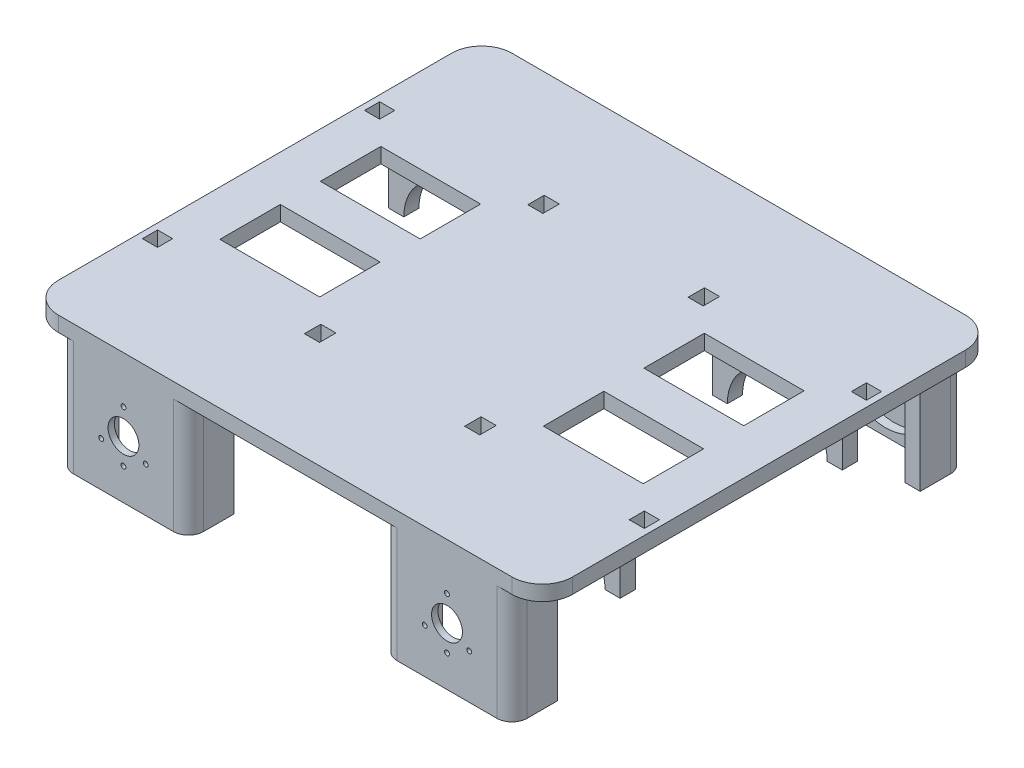
from build123d import *

# Parameters (mm, degrees)
SKETCH1_W                        = 170
SKETCH1_H                        = 150
BOSS_EXTRUDE1_DEPTH              = 5
FILLET1_R                        = 10
BOSS_EXTRUDE2_DEPTH              = 38
SKETCH29_W                       = 43
SKETCH29_H                       = 5
BOSS_EXTRUDE3_DEPTH              = 19
CUT_EXTRUDE1_START               = -2.9
SKETCH6_R                        = 16.5
CUT_EXTRUDE1_DEPTH               = 93.9
SKETCH13_R                       = 5.1
CUT_EXTRUDE2_DEPTH               = 4.7
TAP_DRILL_FOR_M2_TAP1_AT_2_COUNT = 2
TAP_DRILL_FOR_M2_TAP1_AT_2_PITCH = 8.5
TAP_DRILL_FOR_M2_TAP1_AT_3_COUNT = 2
TAP_DRILL_FOR_M2_TAP1_AT_3_PITCH = 14.722431864
TAP_DRILL_FOR_M2_TAP1_AT_4_COUNT = 2
TAP_DRILL_FOR_M2_TAP1_AT_4_PITCH = 14.722431864
FILLET2_R                        = 5
SKETCH28_W                       = 33
SKETCH28_H                       = 20
CUT_EXTRUDE3_DEPTH               = 10
MIRROR25_COPY_1_DEPTH            = 38
MIRROR25_COPY_2_DEPTH            = 38
MIRROR25_START                   = -2.9
MIRROR25_COPY_3_SKETCH_R         = 16.5
MIRROR25_COPY_3_DEPTH            = 93.9
MIRROR25_COPY_4_SKETCH_R         = 5.1
MIRROR25_COPY_4_DEPTH            = 4.7
MIRROR25_COPY_5_SKETCH_R         = 16.5
MIRROR25_COPY_5_DEPTH            = 93.9
MIRROR25_COPY_6_SKETCH_R         = 5.1
MIRROR25_COPY_6_DEPTH            = 4.7
MIRROR25_COPY_15_SKETCH_W        = 33
MIRROR25_COPY_15_SKETCH_H        = 20
MIRROR25_COPY_15_DEPTH           = 10
MIRROR25_COPY_16_SKETCH_W        = 33
MIRROR25_COPY_16_SKETCH_H        = 20
MIRROR25_COPY_16_DEPTH           = 10
FILLET4_R                        = 5
SKETCH33_W                       = 5
SKETCH33_H                       = 5.425553346
CUT_EXTRUDE4_DEPTH               = 10
CUT_EXTRUDE5_START               = -11
SKETCH34_W                       = 5
SKETCH34_H                       = 5
CUT_EXTRUDE5_DEPTH               = 28
MIRROR29_COPY_1_SKETCH_W         = 43
MIRROR29_COPY_1_SKETCH_H         = 5
MIRROR29_COPY_1_DEPTH            = 19
MIRROR29_START                   = -2.9
MIRROR29_COPY_2_SKETCH_R         = 16.5
MIRROR29_COPY_2_DEPTH            = 93.9
MIRROR29_COPY_3_SKETCH_W         = 5
MIRROR29_COPY_3_SKETCH_H         = 5.425553346
MIRROR29_COPY_3_DEPTH            = 10
MIRROR29_START_2                 = -11
MIRROR29_COPY_4_SKETCH_W         = 5
MIRROR29_COPY_4_SKETCH_H         = 5
MIRROR29_COPY_4_DEPTH            = 28
MIRROR29_COPY_5_SKETCH_W         = 43
MIRROR29_COPY_5_SKETCH_H         = 5
MIRROR29_COPY_5_DEPTH            = 19
MIRROR29_COPY_6_SKETCH_R         = 16.5
MIRROR29_COPY_6_DEPTH            = 93.9
MIRROR29_COPY_7_SKETCH_W         = 5
MIRROR29_COPY_7_SKETCH_H         = 5.425553346
MIRROR29_COPY_7_DEPTH            = 10
MIRROR29_COPY_8_SKETCH_W         = 5
MIRROR29_COPY_8_SKETCH_H         = 5
MIRROR29_COPY_8_DEPTH            = 28


with BuildPart() as part:
    # Sketch1 → Boss-Extrude1 (new body)
    with BuildSketch(Plane(origin=(0, 0, 0), x_dir=(1, 0, 0), z_dir=(0, 1, 0))):
        Rectangle(SKETCH1_W, SKETCH1_H)
    extrude(amount=BOSS_EXTRUDE1_DEPTH)

    # Fillet1
    fillet1_edges = [part.edges().sort_by_distance(p)[0] for p in [
        (-85, 2.5, 75),
        (85, 2.5, 75),
        (85, 2.5, -75),
        (-85, 2.5, -75),
    ]]
    fillet(fillet1_edges, radius=FILLET1_R)

    # Sketch3 → Boss-Extrude2 (add)
    with BuildSketch(Plane.XZ):
        Polygon((-75, 75), (-75, 60), (-70, 60), (-70, 70), (-37, 70), (-37, 60), (-32, 60), (-32, 75), align=None)
    boss_extrude2 = extrude(amount=BOSS_EXTRUDE2_DEPTH)

    # Sketch29 → Boss-Extrude3 (add)
    with BuildSketch(Plane.XZ):
        with Locations((-53.5, 36.727703087)):
            Rectangle(SKETCH29_W, SKETCH29_H)
    boss_extrude3 = extrude(amount=BOSS_EXTRUDE3_DEPTH)

    # Sketch6 → Cut-Extrude1 (cut)
    with BuildSketch(Plane(origin=(0, 0, 70), x_dir=(-1, 0, 0), z_dir=(0, 0, -1)).offset(CUT_EXTRUDE1_START)):
        with Locations((53.5, -19)):
            Circle(SKETCH6_R)
    cut_extrude1 = extrude(amount=CUT_EXTRUDE1_DEPTH, mode=Mode.SUBTRACT)

    # Sketch13 → Cut-Extrude2 (cut)
    with BuildSketch(Plane(origin=(0, 0, 72.9), x_dir=(-1, 0, 0), z_dir=(0, 0, -1))):
        with Locations((53.5, -19)):
            Circle(SKETCH13_R)
    cut_extrude2 = extrude(amount=-CUT_EXTRUDE2_DEPTH, mode=Mode.SUBTRACT)

    # Sketch16 → Tap Drill for M2 Tap1 (revolve, cut)
    with BuildSketch(Plane(origin=(-46.138784068, -23.25, 72.9), x_dir=(0, 1, 0), z_dir=(1, 0, 0))):
        Polygon((0, 0), (0, 4.080688495), (0.8, 3.6), (0.8, 0), align=None)
    tap_drill_for_m2_tap1 = revolve(axis=Axis((-46.138784068, -23.25, 66.55), (0, 0, 1)), mode=Mode.SUBTRACT)

    # Tap Drill for M2 Tap1 at 2: Tap Drill for M2 Tap1 ×2
    with Locations(*[Vector(-0.86602540378444, -0.49999999999999756, 0) * (i * TAP_DRILL_FOR_M2_TAP1_AT_2_PITCH) for i in range(1, TAP_DRILL_FOR_M2_TAP1_AT_2_COUNT)]):
        add(tap_drill_for_m2_tap1, mode=Mode.SUBTRACT)

    # Tap Drill for M2 Tap1 at 3: Tap Drill for M2 Tap1 ×2
    with Locations(*[(-i * TAP_DRILL_FOR_M2_TAP1_AT_3_PITCH, 0, 0) for i in range(1, TAP_DRILL_FOR_M2_TAP1_AT_3_COUNT)]):
        add(tap_drill_for_m2_tap1, mode=Mode.SUBTRACT)

    # Tap Drill for M2 Tap1 at 4: Tap Drill for M2 Tap1 ×2
    with Locations(*[Vector(-0.49999999999999784, 0.8660254037844399, 0) * (i * TAP_DRILL_FOR_M2_TAP1_AT_4_PITCH) for i in range(1, TAP_DRILL_FOR_M2_TAP1_AT_4_COUNT)]):
        add(tap_drill_for_m2_tap1, mode=Mode.SUBTRACT)

    # Fillet2
    fillet2_edges = [part.edges().sort_by_distance(p)[0] for p in [
        (-32, -19, 75),
        (-75, -19, 75),
    ]]
    fillet(fillet2_edges, radius=FILLET2_R)

    # Sketch28 → Cut-Extrude3 (cut)
    with BuildSketch(Plane.XZ):
        with Locations((-53.5, 16.617641144)):
            Rectangle(SKETCH28_W, SKETCH28_H)
    cut_extrude3 = extrude(amount=-CUT_EXTRUDE3_DEPTH, mode=Mode.SUBTRACT)

    # Mirror14: Boss-Extrude2 across plane
    add(boss_extrude2.mirror(Plane.XY))

    # Mirror15: Cut-Extrude1, Cut-Extrude2 across plane
    add(cut_extrude1.mirror(Plane.XY), mode=Mode.SUBTRACT)
    add(cut_extrude2.mirror(Plane.XY), mode=Mode.SUBTRACT)

    # Mirror16: Tap Drill for M2 Tap1 across plane
    add(tap_drill_for_m2_tap1.mirror(Plane.XY), mode=Mode.SUBTRACT)

    # Mirror16 copy 1 sketch → Mirror16 copy 1 (revolve, cut)
    with BuildSketch(Plane(origin=(-53.5, -27.5, -72.9), x_dir=(0, 1, 0), z_dir=(1, 0, 0))):
        Polygon((0, 0), (0, -4.080688495), (0.8, -3.6), (0.8, 0), align=None)
    revolve(axis=Axis((-53.5, -27.5, -66.55), (0, 0, 1)), mode=Mode.SUBTRACT)

    # Mirror16 copy 2 sketch → Mirror16 copy 2 (revolve, cut)
    with BuildSketch(Plane(origin=(-60.861215932, -23.25, -72.9), x_dir=(0, 1, 0), z_dir=(1, 0, 0))):
        Polygon((0, 0), (0, -4.080688495), (0.8, -3.6), (0.8, 0), align=None)
    revolve(axis=Axis((-60.861215932, -23.25, -66.55), (0, 0, 1)), mode=Mode.SUBTRACT)

    # Mirror16 copy 3 sketch → Mirror16 copy 3 (revolve, cut)
    with BuildSketch(Plane(origin=(-53.5, -10.5, -72.9), x_dir=(0, 1, 0), z_dir=(1, 0, 0))):
        Polygon((0, 0), (0, -4.080688495), (0.8, -3.6), (0.8, 0), align=None)
    revolve(axis=Axis((-53.5, -10.5, -66.55), (0, 0, 1)), mode=Mode.SUBTRACT)

    # Mirror24: Cut-Extrude3 across plane
    add(cut_extrude3.mirror(Plane.XY), mode=Mode.SUBTRACT)

    # Mirror25 copy 1 sketch → Mirror25 copy 1 (add)
    with BuildSketch(Plane(origin=(0, 0, 0), x_dir=(-1, 0, 0), z_dir=(0, -1, 0))):
        Polygon((-75, 75), (-75, 60), (-70, 60), (-70, 70), (-37, 70), (-37, 60), (-32, 60), (-32, 75), align=None)
    extrude(amount=MIRROR25_COPY_1_DEPTH)

    # Mirror25 copy 2 sketch → Mirror25 copy 2 (add)
    with BuildSketch(Plane(origin=(0, 0, 0), x_dir=(-1, 0, 0), z_dir=(0, -1, 0))):
        Polygon((-75, -75), (-75, -60), (-70, -60), (-70, -70), (-37, -70), (-37, -60), (-32, -60), (-32, -75), align=None)
    extrude(amount=MIRROR25_COPY_2_DEPTH)

    # Mirror25 copy 3 sketch → Mirror25 copy 3 (cut)
    with BuildSketch(Plane.XY.offset(-70).offset(MIRROR25_START)):
        with Locations((53.5, -19)):
            Circle(MIRROR25_COPY_3_SKETCH_R)
    extrude(amount=MIRROR25_COPY_3_DEPTH, mode=Mode.SUBTRACT)

    # Mirror25 copy 4 sketch → Mirror25 copy 4 (cut)
    with BuildSketch(Plane.XY.offset(-72.9)):
        with Locations((53.5, -19)):
            Circle(MIRROR25_COPY_4_SKETCH_R)
    extrude(amount=-MIRROR25_COPY_4_DEPTH, mode=Mode.SUBTRACT)

    # Mirror25 copy 5 sketch → Mirror25 copy 5 (cut)
    with BuildSketch(Plane(origin=(0, 0, 70), x_dir=(1, 0, 0), z_dir=(0, 0, -1)).offset(MIRROR25_START)):
        with Locations((53.5, 19)):
            Circle(MIRROR25_COPY_5_SKETCH_R)
    extrude(amount=MIRROR25_COPY_5_DEPTH, mode=Mode.SUBTRACT)

    # Mirror25 copy 6 sketch → Mirror25 copy 6 (cut)
    with BuildSketch(Plane(origin=(0, 0, 72.9), x_dir=(1, 0, 0), z_dir=(0, 0, -1))):
        with Locations((53.5, 19)):
            Circle(MIRROR25_COPY_6_SKETCH_R)
    extrude(amount=-MIRROR25_COPY_6_DEPTH, mode=Mode.SUBTRACT)

    # Mirror25 copy 7 sketch → Mirror25 copy 7 (revolve, cut)
    with BuildSketch(Plane(origin=(46.138784068, -23.25, -72.9), x_dir=(0, 1, 0), z_dir=(-1, 0, 0))):
        Polygon((0, 0), (0, 4.080688495), (0.8, 3.6), (0.8, 0), align=None)
    revolve(axis=Axis((46.138784068, -23.25, -66.55), (0, 0, -1)), mode=Mode.SUBTRACT)

    # Mirror25 copy 8 sketch → Mirror25 copy 8 (revolve, cut)
    with BuildSketch(Plane(origin=(53.5, -27.5, -72.9), x_dir=(0, 1, 0), z_dir=(-1, 0, 0))):
        Polygon((0, 0), (0, 4.080688495), (0.8, 3.6), (0.8, 0), align=None)
    revolve(axis=Axis((53.5, -27.5, -66.55), (0, 0, -1)), mode=Mode.SUBTRACT)

    # Mirror25 copy 9 sketch → Mirror25 copy 9 (revolve, cut)
    with BuildSketch(Plane(origin=(60.861215932, -23.25, -72.9), x_dir=(0, 1, 0), z_dir=(-1, 0, 0))):
        Polygon((0, 0), (0, 4.080688495), (0.8, 3.6), (0.8, 0), align=None)
    revolve(axis=Axis((60.861215932, -23.25, -66.55), (0, 0, -1)), mode=Mode.SUBTRACT)

    # Mirror25 copy 10 sketch → Mirror25 copy 10 (revolve, cut)
    with BuildSketch(Plane(origin=(53.5, -10.5, -72.9), x_dir=(0, 1, 0), z_dir=(-1, 0, 0))):
        Polygon((0, 0), (0, 4.080688495), (0.8, 3.6), (0.8, 0), align=None)
    revolve(axis=Axis((53.5, -10.5, -66.55), (0, 0, -1)), mode=Mode.SUBTRACT)

    # Mirror25 copy 11 sketch → Mirror25 copy 11 (revolve, cut)
    with BuildSketch(Plane(origin=(46.138784068, -23.25, 72.9), x_dir=(0, 1, 0), z_dir=(-1, 0, 0))):
        Polygon((0, 0), (0, -4.080688495), (0.8, -3.6), (0.8, 0), align=None)
    revolve(axis=Axis((46.138784068, -23.25, 66.55), (0, 0, -1)), mode=Mode.SUBTRACT)

    # Mirror25 copy 12 sketch → Mirror25 copy 12 (revolve, cut)
    with BuildSketch(Plane(origin=(53.5, -27.5, 72.9), x_dir=(0, 1, 0), z_dir=(-1, 0, 0))):
        Polygon((0, 0), (0, -4.080688495), (0.8, -3.6), (0.8, 0), align=None)
    revolve(axis=Axis((53.5, -27.5, 66.55), (0, 0, -1)), mode=Mode.SUBTRACT)

    # Mirror25 copy 13 sketch → Mirror25 copy 13 (revolve, cut)
    with BuildSketch(Plane(origin=(60.861215932, -23.25, 72.9), x_dir=(0, 1, 0), z_dir=(-1, 0, 0))):
        Polygon((0, 0), (0, -4.080688495), (0.8, -3.6), (0.8, 0), align=None)
    revolve(axis=Axis((60.861215932, -23.25, 66.55), (0, 0, -1)), mode=Mode.SUBTRACT)

    # Mirror25 copy 14 sketch → Mirror25 copy 14 (revolve, cut)
    with BuildSketch(Plane(origin=(53.5, -10.5, 72.9), x_dir=(0, 1, 0), z_dir=(-1, 0, 0))):
        Polygon((0, 0), (0, -4.080688495), (0.8, -3.6), (0.8, 0), align=None)
    revolve(axis=Axis((53.5, -10.5, 66.55), (0, 0, -1)), mode=Mode.SUBTRACT)

    # Mirror25 copy 15 sketch → Mirror25 copy 15 (cut)
    with BuildSketch(Plane(origin=(0, 0, 0), x_dir=(-1, 0, 0), z_dir=(0, -1, 0))):
        with Locations((-53.5, 16.617641144)):
            Rectangle(MIRROR25_COPY_15_SKETCH_W, MIRROR25_COPY_15_SKETCH_H)
    extrude(amount=-MIRROR25_COPY_15_DEPTH, mode=Mode.SUBTRACT)

    # Mirror25 copy 16 sketch → Mirror25 copy 16 (cut)
    with BuildSketch(Plane(origin=(0, 0, 0), x_dir=(-1, 0, 0), z_dir=(0, -1, 0))):
        with Locations((-53.5, -16.617641144)):
            Rectangle(MIRROR25_COPY_16_SKETCH_W, MIRROR25_COPY_16_SKETCH_H)
    extrude(amount=-MIRROR25_COPY_16_DEPTH, mode=Mode.SUBTRACT)

    # Fillet4
    fillet4_edges = [part.edges().sort_by_distance(p)[0] for p in [
        (32, -19, -75),
        (75, -19, -75),
        (-32, -19, -75),
        (-75, -19, -75),
        (32, -19, 75),
        (75, -19, 75),
    ]]
    fillet(fillet4_edges, radius=FILLET4_R)

    # Sketch33 → Cut-Extrude4 (cut)
    with BuildSketch(Plane.XZ):
        with Locations((-26.5, 36.94047976)):
            Rectangle(SKETCH33_W, SKETCH33_H)
    cut_extrude4 = extrude(amount=-CUT_EXTRUDE4_DEPTH, mode=Mode.SUBTRACT)

    # Sketch34 → Cut-Extrude5 (cut)
    with BuildSketch(Plane(origin=(0, 5, 0), x_dir=(1, 0, 0), z_dir=(0, 1, 0)).offset(CUT_EXTRUDE5_START)):
        with Locations((-80.5, -36.727703087)):
            Rectangle(SKETCH34_W, SKETCH34_H)
    cut_extrude5 = extrude(amount=CUT_EXTRUDE5_DEPTH, mode=Mode.SUBTRACT)

    # Mirror28: Boss-Extrude3, Cut-Extrude1, Cut-Extrude4, Cut-Extrude5 across plane
    add(boss_extrude3.mirror(Plane.XY))
    add(cut_extrude1.mirror(Plane.XY), mode=Mode.SUBTRACT)
    add(cut_extrude4.mirror(Plane.XY), mode=Mode.SUBTRACT)
    add(cut_extrude5.mirror(Plane.XY), mode=Mode.SUBTRACT)

    # Mirror29 copy 1 sketch → Mirror29 copy 1 (add)
    with BuildSketch(Plane(origin=(0, 0, 0), x_dir=(-1, 0, 0), z_dir=(0, -1, 0))):
        with Locations((-53.5, 36.727703087)):
            Rectangle(MIRROR29_COPY_1_SKETCH_W, MIRROR29_COPY_1_SKETCH_H)
    extrude(amount=MIRROR29_COPY_1_DEPTH)

    # Mirror29 copy 2 sketch → Mirror29 copy 2 (cut)
    with BuildSketch(Plane.XY.offset(-70).offset(MIRROR29_START)):
        with Locations((53.5, -19)):
            Circle(MIRROR29_COPY_2_SKETCH_R)
    extrude(amount=MIRROR29_COPY_2_DEPTH, mode=Mode.SUBTRACT)

    # Mirror29 copy 3 sketch → Mirror29 copy 3 (cut)
    with BuildSketch(Plane(origin=(0, 0, 0), x_dir=(-1, 0, 0), z_dir=(0, -1, 0))):
        with Locations((-26.5, 36.94047976)):
            Rectangle(MIRROR29_COPY_3_SKETCH_W, MIRROR29_COPY_3_SKETCH_H)
    extrude(amount=-MIRROR29_COPY_3_DEPTH, mode=Mode.SUBTRACT)

    # Mirror29 copy 4 sketch → Mirror29 copy 4 (cut)
    with BuildSketch(Plane(origin=(0, 5, 0), x_dir=(-1, 0, 0), z_dir=(0, 1, 0)).offset(MIRROR29_START_2)):
        with Locations((-80.5, -36.727703087)):
            Rectangle(MIRROR29_COPY_4_SKETCH_W, MIRROR29_COPY_4_SKETCH_H)
    extrude(amount=MIRROR29_COPY_4_DEPTH, mode=Mode.SUBTRACT)

    # Mirror29 copy 5 sketch → Mirror29 copy 5 (add)
    with BuildSketch(Plane(origin=(0, 0, 0), x_dir=(-1, 0, 0), z_dir=(0, -1, 0))):
        with Locations((-53.5, -36.727703087)):
            Rectangle(MIRROR29_COPY_5_SKETCH_W, MIRROR29_COPY_5_SKETCH_H)
    extrude(amount=MIRROR29_COPY_5_DEPTH)

    # Mirror29 copy 6 sketch → Mirror29 copy 6 (cut)
    with BuildSketch(Plane(origin=(0, 0, 70), x_dir=(1, 0, 0), z_dir=(0, 0, -1)).offset(MIRROR29_START)):
        with Locations((53.5, 19)):
            Circle(MIRROR29_COPY_6_SKETCH_R)
    extrude(amount=MIRROR29_COPY_6_DEPTH, mode=Mode.SUBTRACT)

    # Mirror29 copy 7 sketch → Mirror29 copy 7 (cut)
    with BuildSketch(Plane(origin=(0, 0, 0), x_dir=(-1, 0, 0), z_dir=(0, -1, 0))):
        with Locations((-26.5, -36.94047976)):
            Rectangle(MIRROR29_COPY_7_SKETCH_W, MIRROR29_COPY_7_SKETCH_H)
    extrude(amount=-MIRROR29_COPY_7_DEPTH, mode=Mode.SUBTRACT)

    # Mirror29 copy 8 sketch → Mirror29 copy 8 (cut)
    with BuildSketch(Plane(origin=(0, 5, 0), x_dir=(-1, 0, 0), z_dir=(0, 1, 0)).offset(MIRROR29_START_2)):
        with Locations((-80.5, 36.727703087)):
            Rectangle(MIRROR29_COPY_8_SKETCH_W, MIRROR29_COPY_8_SKETCH_H)
    extrude(amount=MIRROR29_COPY_8_DEPTH, mode=Mode.SUBTRACT)


solid = part.part
